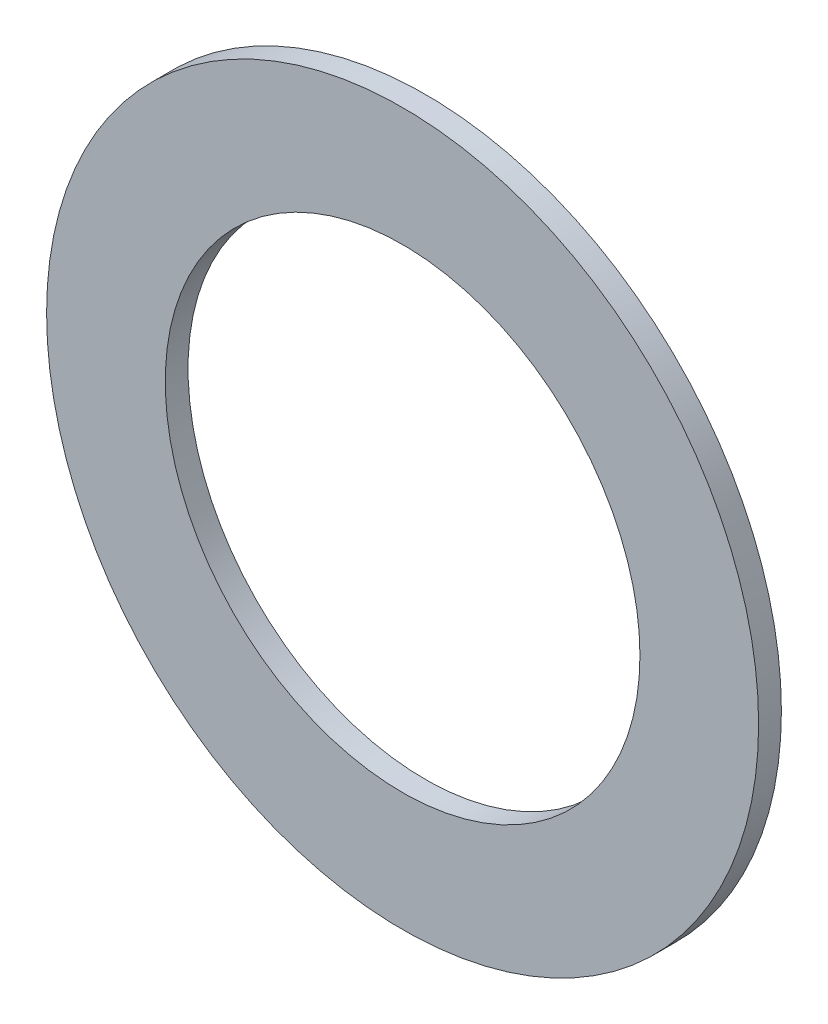
from build123d import *

# Parameters (mm, degrees)
SKETCH1_R           = 4.7625
SKETCH1_R_2         = 3.175
BOSS_EXTRUDE1_DEPTH = 0.3048


with BuildPart() as part:
    # Sketch1 → Boss-Extrude1 (new body)
    with BuildSketch(Plane.XY):
        Circle(SKETCH1_R)
        Circle(SKETCH1_R_2, mode=Mode.SUBTRACT)
    extrude(amount=BOSS_EXTRUDE1_DEPTH)


solid = part.part
